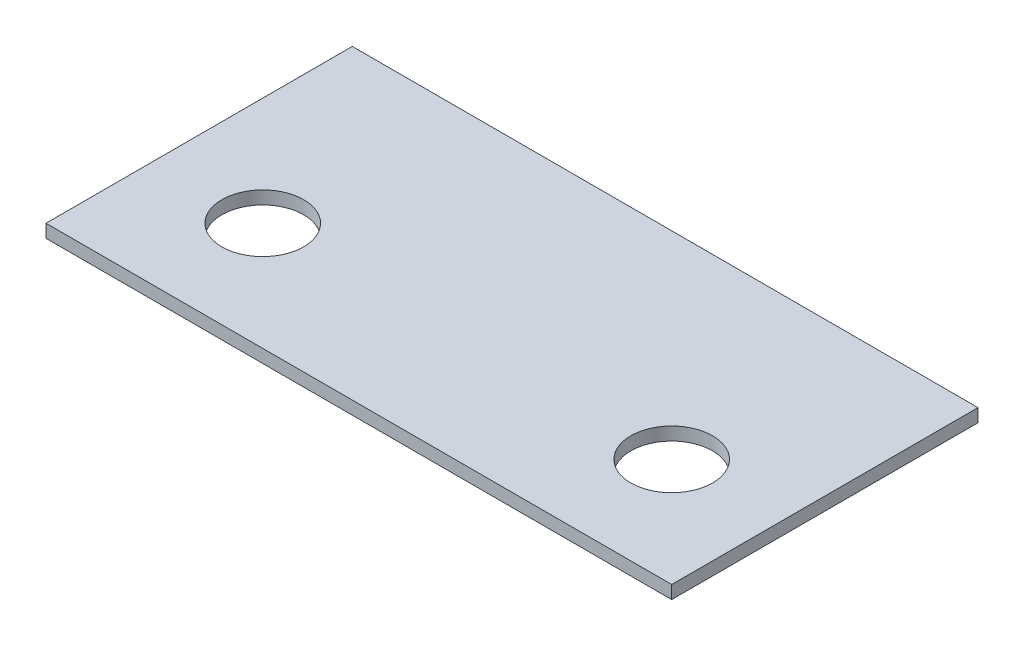
from build123d import *

# Parameters (mm, degrees)
SKETCH1_W                      = 765
SKETCH1_H                      = 374.5
BOSS_EXTRUDE1_DEPTH            = 16
CUT_EXTRUDE1_REACH             = 18
SKETCH2_R                      = 50
CUT_EXTRUDE1_DIRECTION_2_DEPTH = 1


with BuildPart() as part:
    # Sketch1 → Boss-Extrude1 (new body)
    with BuildSketch(Plane(origin=(0, 0, 0), x_dir=(1, 0, 0), z_dir=(0, 1, 0))):
        Rectangle(SKETCH1_W, SKETCH1_H)
    extrude(amount=BOSS_EXTRUDE1_DEPTH)

    # Sketch2 → Cut-Extrude1 (cut, up to next)
    with BuildSketch(Plane(origin=(0, 16, 0), x_dir=(1, 0, 0), z_dir=(0, 1, 0)), mode=Mode.PRIVATE) as cut_extrude1_sk1:
        with Locations((-250, -54.75)):
            Circle(SKETCH2_R)
    cut_extrude1_tool1 = extrude(cut_extrude1_sk1.sketch, amount=-CUT_EXTRUDE1_REACH, mode=Mode.PRIVATE) & part.part
    add(cut_extrude1_tool1.solids().sort_by_distance((-250, 16, 54.75))[0], mode=Mode.SUBTRACT)
    # Sketch2 → Cut-Extrude1 (cut, up to next)
    with BuildSketch(Plane(origin=(0, 16, 0), x_dir=(1, 0, 0), z_dir=(0, 1, 0)), mode=Mode.PRIVATE) as cut_extrude1_sk2:
        with Locations((250, -54.75)):
            Circle(SKETCH2_R)
    cut_extrude1_tool2 = extrude(cut_extrude1_sk2.sketch, amount=-CUT_EXTRUDE1_REACH, mode=Mode.PRIVATE) & part.part
    add(cut_extrude1_tool2.solids().sort_by_distance((250, 16, 54.75))[0], mode=Mode.SUBTRACT)

    # Sketch2 → Cut-Extrude1 direction 2 (cut)
    with BuildSketch(Plane(origin=(0, 16, 0), x_dir=(1, 0, 0), z_dir=(0, 1, 0))):
        with Locations((-250, -54.75)):
            Circle(SKETCH2_R)
        with Locations((250, -54.75)):
            Circle(SKETCH2_R)
    extrude(amount=CUT_EXTRUDE1_DIRECTION_2_DEPTH, mode=Mode.SUBTRACT)


solid = part.part
